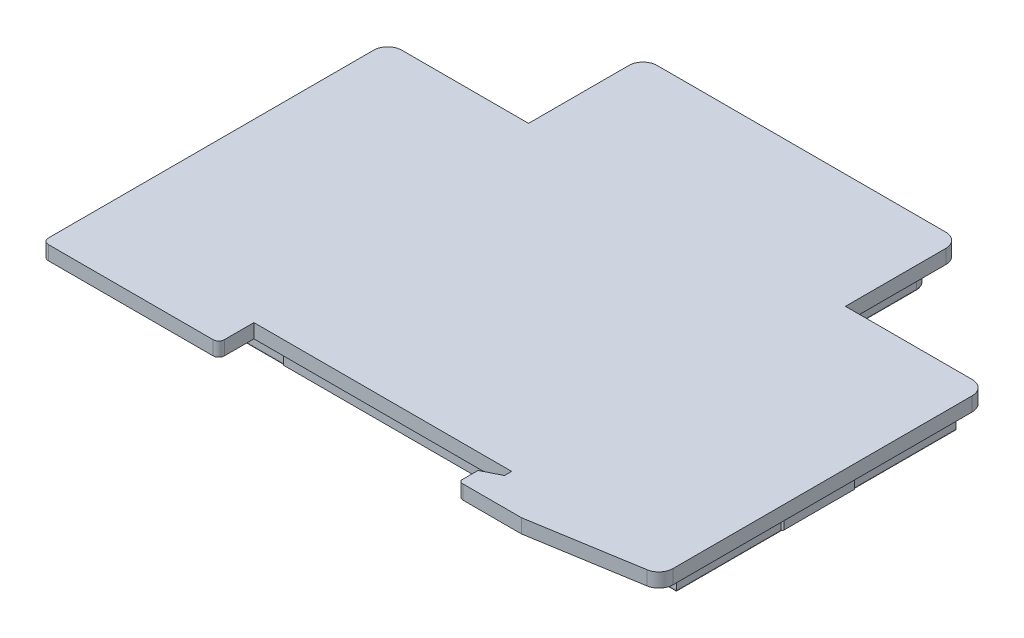
from build123d import *

# Parameters (mm, degrees)
BOSS_EXTRUDE1_DEPTH = 3.3
BOSS_EXTRUDE2_DEPTH = 2
SKETCH5_W           = 10
SKETCH5_H           = 1.55
BOSS_EXTRUDE3_DEPTH = 0.45
SKETCH6_W           = 10
SKETCH6_H           = 1.55
BOSS_EXTRUDE4_DEPTH = 0.45
SKETCH7_W           = 10
SKETCH7_H           = 1.55
BOSS_EXTRUDE5_DEPTH = 0.45
SKETCH8_W           = 10
SKETCH8_H           = 1.55
BOSS_EXTRUDE6_DEPTH = 0.45
SKETCH9_W           = 30
SKETCH9_H           = 1.55
BOSS_EXTRUDE7_DEPTH = 0.45
SKETCH10_W          = 10
SKETCH10_H          = 1.55
BOSS_EXTRUDE8_DEPTH = 0.45
CHAMFER1_SIZE       = 0.2
SKETCH11_W          = 37.2
SKETCH11_H          = 23
CUT_EXTRUDE1_DEPTH  = 1.6
FILLET1_R           = 0.2


with BuildPart() as part:
    # Sketch1 → Boss-Extrude1 (new body)
    with BuildSketch(Plane(origin=(0, 0, 0), x_dir=(1, 0, 0), z_dir=(0, 1, 0))):
        with BuildLine():
            Line((19.586290833, 59.977163541), (19.586290833, 47.727163541))
            ThreePointArc((19.586290833, 47.727163541), (18.956570412, 46.206883961), (17.436290833, 45.577163541))
            Line((17.436290833, 45.577163541), (-0.413709167, 45.577163541))
            Line((-0.413709167, 45.577163541), (-0.413709167, 5.877163541))
            Line((-0.413709167, 5.877163541), (80.286290833, 5.877163541))
            Line((80.286290833, 5.877163541), (80.286290833, 45.577163541))
            Line((80.286290833, 45.577163541), (62.436290833, 45.577163541))
            ThreePointArc((62.436290833, 45.577163541), (60.916011253, 46.206883961), (60.286290833, 47.727163541))
            Line((60.286290833, 47.727163541), (60.286290833, 59.977163541))
            ThreePointArc((60.286290833, 59.977163541), (59.744438378, 61.285311086), (58.436290833, 61.827163541))
            Line((58.436290833, 61.827163541), (21.436290833, 61.827163541))
            ThreePointArc((21.436290833, 61.827163541), (20.128143288, 61.285311086), (19.586290833, 59.977163541))
        make_face()
    extrude(amount=BOSS_EXTRUDE1_DEPTH)

    # Sketch2 → Boss-Extrude2 (add)
    with BuildSketch(Plane(origin=(0, 3.3, 0), x_dir=(1, 0, 0), z_dir=(0, 1, 0))):
        with BuildLine():
            Line((57.136290833, -1.272836459), (65.436290833, -1.272836459))
            Line((65.436290833, -1.272836459), (80.761323353, 1.251286544))
            ThreePointArc((80.761323353, 1.251286544), (81.961096565, 1.930492929), (82.436290833, 3.224698275))
            Line((82.436290833, 3.224698275), (82.436290833, 45.727163541))
            ThreePointArc((82.436290833, 45.727163541), (81.850504395, 47.141377103), (80.436290833, 47.727163541))
            Line((80.436290833, 47.727163541), (66.436290833, 47.727163541))
            Line((66.436290833, 47.727163541), (62.436290833, 47.727163541))
            Line((62.436290833, 47.727163541), (62.436290833, 61.977163541))
            ThreePointArc((62.436290833, 61.977163541), (61.850504395, 63.391377103), (60.436290833, 63.977163541))
            Line((60.436290833, 63.977163541), (19.436290833, 63.977163541))
            ThreePointArc((19.436290833, 63.977163541), (18.022077271, 63.391377103), (17.436290833, 61.977163541))
            Line((17.436290833, 61.977163541), (17.436290833, 47.727163541))
            Line((17.436290833, 47.727163541), (3.436290833, 47.727163541))
            Line((3.436290833, 47.727163541), (-0.563709167, 47.727163541))
            ThreePointArc((-0.563709167, 47.727163541), (-1.977922729, 47.141377103), (-2.563709167, 45.727163541))
            Line((-2.563709167, 45.727163541), (-2.563709167, -0.472836459))
            ThreePointArc((-2.563709167, -0.472836459), (-2.329394592, -1.038521884), (-1.763709167, -1.272836459))
            Line((-1.763709167, -1.272836459), (21.636290833, -1.272836459))
            ThreePointArc((21.636290833, -1.272836459), (22.201976258, -1.038521884), (22.436290833, -0.472836459))
            Line((22.436290833, -0.472836459), (22.436290833, 3.727163541))
            Line((22.436290833, 3.727163541), (59.036290833, 3.727163541))
            Line((59.036290833, 3.727163541), (59.036290833, 2.703556743))
            Line((59.036290833, 2.703556743), (56.536290833, 1.453556743))
            Line((56.536290833, 1.453556743), (56.536290833, -1.001986721))
            ThreePointArc((56.536290833, -1.001986721), (56.807140571, -1.201986721), (57.136290833, -1.272836459))
        make_face()
    extrude(amount=BOSS_EXTRUDE2_DEPTH)

    # Sketch5 → Boss-Extrude3 (add)
    with BuildSketch(Plane(origin=(0, 0, -45.577163541), x_dir=(-1, 0, 0), z_dir=(0, 0, -1))):
        with Locations((-71.436290833, 1.025)):
            Rectangle(SKETCH5_W, SKETCH5_H)
        with Locations((-8.436290833, 1.025)):
            Rectangle(SKETCH5_W, SKETCH5_H)
    extrude(amount=BOSS_EXTRUDE3_DEPTH)

    # Sketch6 → Boss-Extrude4 (add)
    with BuildSketch(Plane(origin=(0, 0, -61.827163541), x_dir=(-1, 0, 0), z_dir=(0, 0, -1))):
        with Locations((-39.936290833, 1.025)):
            Rectangle(SKETCH6_W, SKETCH6_H)
    extrude(amount=BOSS_EXTRUDE4_DEPTH)

    # Sketch7 → Boss-Extrude5 (add)
    with BuildSketch(Plane(origin=(-0.413709167, 0, 0.363709167), x_dir=(0, 0, 1), z_dir=(-1, 0, 0))):
        with Locations((-26.090872708, 1.025)):
            Rectangle(SKETCH7_W, SKETCH7_H)
    extrude(amount=BOSS_EXTRUDE5_DEPTH)

    # Sketch8 → Boss-Extrude6 (add)
    with BuildSketch(Plane(origin=(80.286290833, 0, -80.236290833), x_dir=(0, 0, 1), z_dir=(-1, 0, 0))):
        with Locations((54.509127292, 1.025)):
            Rectangle(SKETCH8_W, SKETCH8_H)
    extrude(amount=BOSS_EXTRUDE6_DEPTH)

    # Sketch9 → Boss-Extrude7 (add)
    with BuildSketch(Plane.XY.offset(-5.877163541)):
        with Locations((39.936290833, 1.025)):
            Rectangle(SKETCH9_W, SKETCH9_H)
    extrude(amount=BOSS_EXTRUDE7_DEPTH)

    # Sketch10 → Boss-Extrude8 (add)
    with BuildSketch(Plane(origin=(80.286290833, 0, 0), x_dir=(0, 0, -1), z_dir=(1, 0, 0))):
        with Locations((25.727163541, 1.025)):
            Rectangle(SKETCH10_W, SKETCH10_H)
    extrude(amount=BOSS_EXTRUDE8_DEPTH)

    # Chamfer1
    chamfer1_edges = [part.edges().sort_by_distance(p)[0] for p in [
        (8.436290833, 1.8, -46.027163541),
        (8.436290833, 0.25, -46.027163541),
        (39.936290833, 0.25, -62.277163541),
        (39.936290833, 1.8, -62.277163541),
        (-0.863709167, 0.25, -25.727163541),
        (-0.863709167, 1.8, -25.727163541),
        (39.936290833, 1.8, -5.427163541),
        (39.936290833, 0.25, -5.427163541),
        (80.736290833, 0.25, -25.727163541),
        (80.736290833, 1.8, -25.727163541),
        (71.436290833, 0.25, -46.027163541),
        (71.436290833, 1.8, -46.027163541),
    ]]
    chamfer(chamfer1_edges, length=CHAMFER1_SIZE)

    # Sketch11 → Cut-Extrude1 (cut)
    with BuildSketch(Plane(origin=(0, 0, 0), x_dir=(-1, 0, 0), z_dir=(0, -1, 0))):
        with Locations((-29.296290833, 28.397163541)):
            Rectangle(SKETCH11_W, SKETCH11_H)
    extrude(amount=-CUT_EXTRUDE1_DEPTH, mode=Mode.SUBTRACT)

    # Fillet1
    fillet1_edges = [part.edges().sort_by_distance(p)[0] for p in [
        (19.586290833, 0, -53.852163541),
        (20.128143288, 0, -61.285311086),
        (39.936290833, 0, -61.827163541),
        (59.744438378, 0, -61.285311086),
        (60.286290833, 0, -53.852163541),
        (60.916011253, 0, -46.206883961),
        (71.361290833, 0, -45.577163541),
        (80.286290833, 0, -25.727163541),
        (39.936290833, 0, -5.877163541),
        (-0.413709167, 0, -25.727163541),
        (8.511290833, 0, -45.577163541),
        (18.956570412, 0, -46.206883961),
        (29.296290833, 0, -16.897163541),
        (10.696290833, 0, -28.397163541),
        (29.296290833, 0, -39.897163541),
        (47.896290833, 0, -28.397163541),
    ]]
    fillet(fillet1_edges, radius=FILLET1_R)


solid = part.part
